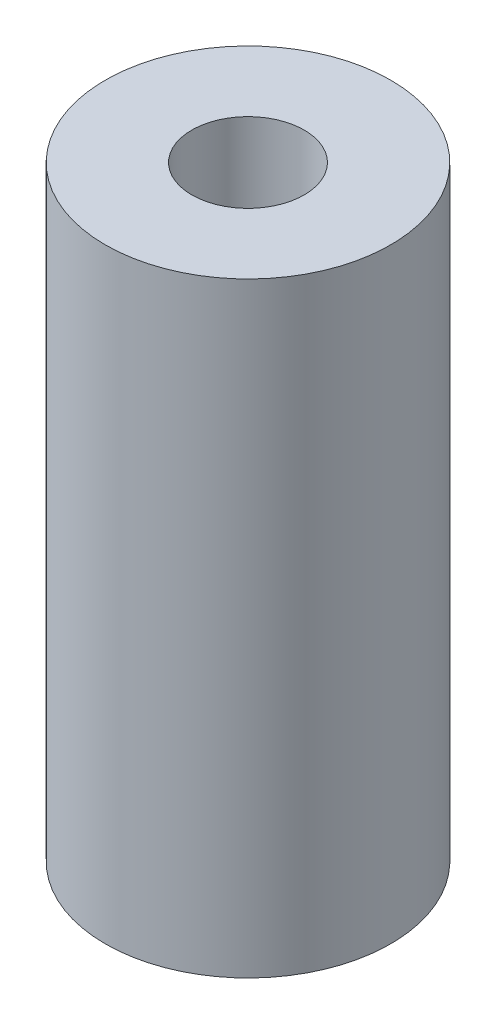
from build123d import *

# Parameters (mm, degrees)
SKETCH1_R           = 4.191
SKETCH1_R_2         = 1.651
BOSS_EXTRUDE1_DEPTH = 17.78


with BuildPart() as part:
    # Sketch1 → Boss-Extrude1 (new body)
    with BuildSketch(Plane(origin=(0, 0, 0), x_dir=(1, 0, 0), z_dir=(0, 1, 0))):
        Circle(SKETCH1_R)
        Circle(SKETCH1_R_2, mode=Mode.SUBTRACT)
    extrude(amount=BOSS_EXTRUDE1_DEPTH)


solid = part.part
